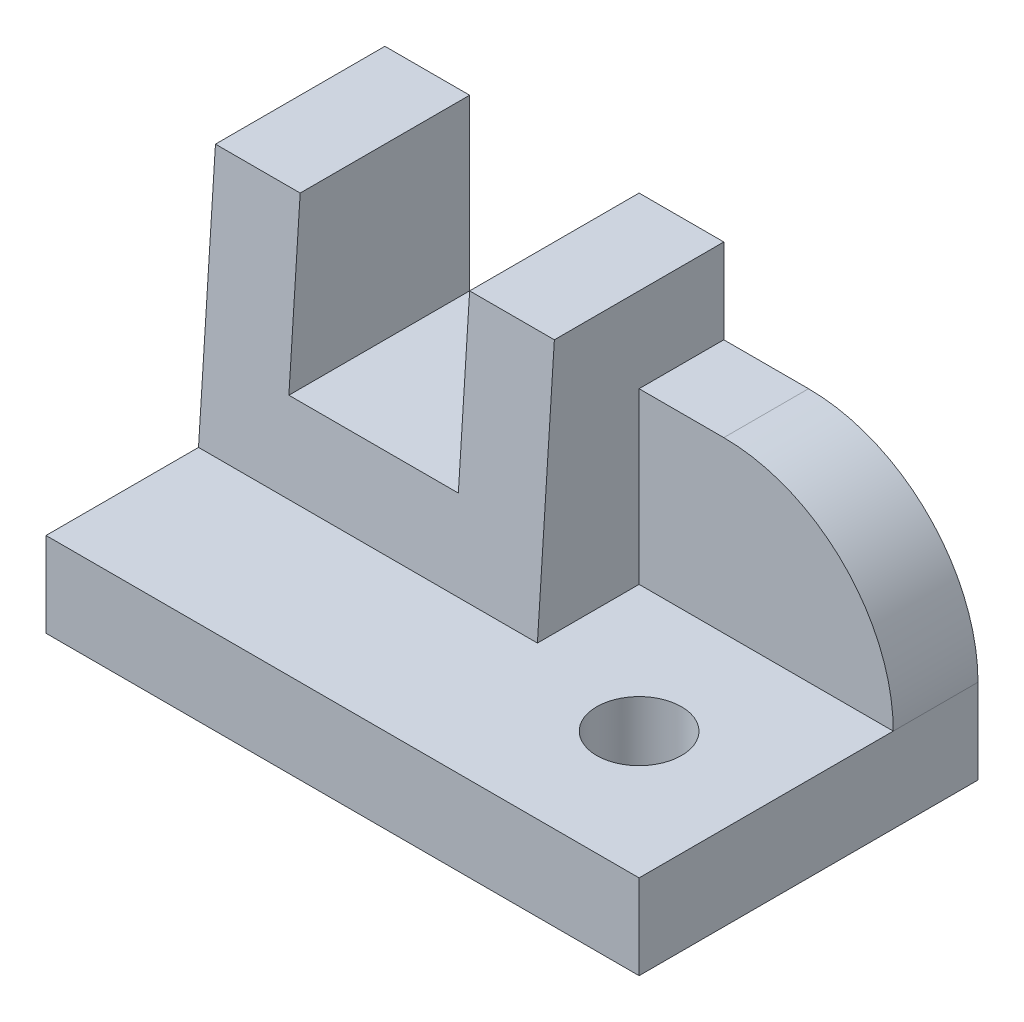
from build123d import *

# Parameters (mm, degrees)
BOSS_EXTRUDE1_DEPTH            = 40
SKETCH2_W                      = 40
SKETCH2_H                      = 30
BOSS_EXTRUDE2_DEPTH            = 20
BOSS_EXTRUDE3_DEPTH            = 30
CUT_EXTRUDE1_DEPTH             = 30
SKETCH5_W                      = 70
SKETCH5_H                      = 40
BOSS_EXTRUDE4_DEPTH            = 10
SKETCH6_W                      = 20
SKETCH6_H                      = 20
CUT_EXTRUDE2_DEPTH             = 41
F_10_0_10_DIAMETER_HOLE1_D     = 10
F_10_0_10_DIAMETER_HOLE1_DEPTH = 40
FILLET1_R                      = 20


with BuildPart() as part:
    # Sketch1 → Boss-Extrude1 (new body)
    with BuildSketch(Plane(origin=(0, 0, 0), x_dir=(0, -1, 0), z_dir=(-1, 0, 0))):
        Polygon((-10, -18), (-40, -20), (-10, -20), align=None)
    extrude(amount=-BOSS_EXTRUDE1_DEPTH)

    # Sketch2 → Boss-Extrude2 (add)
    with BuildSketch(Plane(origin=(0, 0, -20), x_dir=(-1, 0, 0), z_dir=(0, 0, -1))):
        with Locations((-20, 25)):
            Rectangle(SKETCH2_W, SKETCH2_H)
    extrude(amount=BOSS_EXTRUDE2_DEPTH)

    # Sketch3 → Boss-Extrude3 (add)
    with BuildSketch(Plane(origin=(40, 0, 0), x_dir=(0, 0, -1), z_dir=(1, 0, 0))):
        Polygon((40, 10), (0, 10), (20, 40), (40, 40), align=None)
    extrude(amount=BOSS_EXTRUDE3_DEPTH)

    # Sketch4 → Cut-Extrude1 (cut)
    with BuildSketch(Plane(origin=(70, 0, 0), x_dir=(0, 0, -1), z_dir=(1, 0, 0))):
        Polygon((20, 40), (0, 10), (30, 10), (30, 30), (40, 30), (40, 40), align=None)
    extrude(amount=-CUT_EXTRUDE1_DEPTH, mode=Mode.SUBTRACT)

    # Sketch5 → Boss-Extrude4 (add)
    with BuildSketch(Plane.XZ.offset(-10)):
        with Locations((35, -20)):
            Rectangle(SKETCH5_W, SKETCH5_H)
    extrude(amount=BOSS_EXTRUDE4_DEPTH)

    # Sketch6 → Cut-Extrude2 (cut, through all)
    with BuildSketch(Plane(origin=(0, 0, -40), x_dir=(-1, 0, 0), z_dir=(0, 0, -1))):
        with Locations((-20, 30)):
            Rectangle(SKETCH6_W, SKETCH6_H)
    extrude(amount=-CUT_EXTRUDE2_DEPTH, mode=Mode.SUBTRACT)

    # Ø10.0 (10) Diameter Hole1
    with Locations(Plane(origin=(0, 0, 0), x_dir=(-1, 0, 0), z_dir=(0, -1, 0))):
        with Locations((-55, 15)):
            Hole(F_10_0_10_DIAMETER_HOLE1_D / 2, depth=F_10_0_10_DIAMETER_HOLE1_DEPTH)

    # Fillet1
    fillet1_edges = [part.edges().sort_by_distance(p)[0] for p in [
        (70, 30, -35),
    ]]
    fillet(fillet1_edges, radius=FILLET1_R)


solid = part.part
